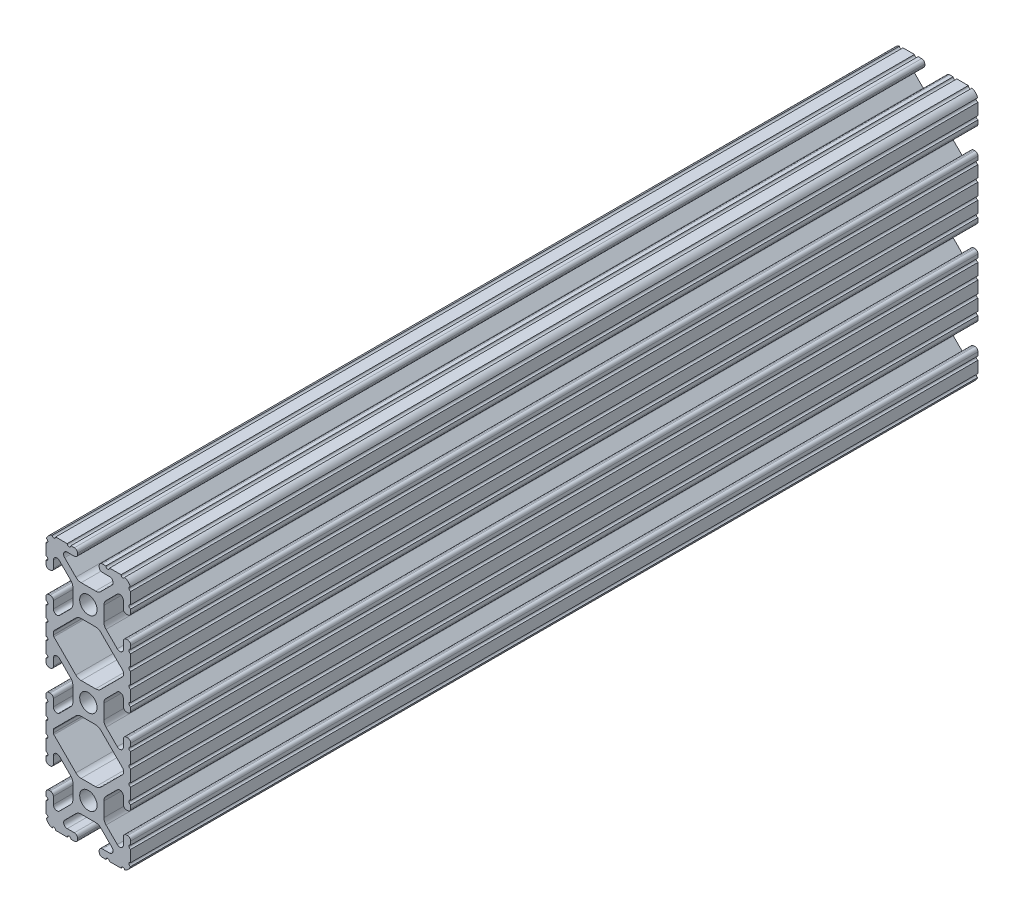
from build123d import *

# Parameters (mm, degrees)
BOSS_EXTRUDE1_DEPTH     = 127
SKETCH5_R               = 0.55245
CUT_EXTRUDE1_DEPTH      = 134.198723718
CUT_EXTRUDE1_DEPTH_BACK = 134.198723718
BOSS_EXTRUDE2_DEPTH     = 127
CUT_EXTRUDE2_DEPTH      = 134.198723718
CUT_EXTRUDE2_DEPTH_BACK = 134.198723718


with BuildPart() as part:
    # Sketch4 → Boss-Extrude1 (new, symmetric)
    with BuildSketch(Plane.XY):
        with BuildLine():
            Line((4.190365, -38.1), (10.11729625, -38.1))
            ThreePointArc((10.11729625, -38.1), (11.943543585, -37.343543585), (12.7, -35.51729625))
            Line((12.7, -35.51729625), (12.7, -29.590365))
            ThreePointArc((12.7, -29.590365), (12.42492494, -28.92627506), (11.760835, -28.6512))
            Line((11.760835, -28.6512), (11.429365, -28.6512))
            ThreePointArc((11.429365, -28.6512), (10.76527506, -28.92627506), (10.4902, -29.590365))
            Line((10.4902, -29.590365), (10.4902, -31.748478019))
            ThreePointArc((10.4902, -31.748478019), (9.830707141, -32.735478831), (8.666460301, -32.503895736))
            Line((8.666460301, -32.503895736), (5.299899128, -29.137334563))
            ThreePointArc((5.299899128, -29.137334563), (4.817571085, -28.415479634), (4.6482, -27.56399369))
            Line((4.6482, -27.56399369), (4.6482, -25.4))
            Line((4.6482, -25.4), (2.6035, -25.4))
            ThreePointArc((2.6035, -25.4), (1.840952505, -27.240952505), (0, -28.0035))
            Line((0, -28.0035), (0, -30.0482))
            Line((0, -30.0482), (2.16399369, -30.0482))
            ThreePointArc((2.16399369, -30.0482), (3.015479634, -30.217571085), (3.737334563, -30.699899128))
            Line((3.737334563, -30.699899128), (7.103895736, -34.066460301))
            ThreePointArc((7.103895736, -34.066460301), (7.335478831, -35.230707141), (6.348478019, -35.8902))
            Line((6.348478019, -35.8902), (4.190365, -35.8902))
            ThreePointArc((4.190365, -35.8902), (3.52627506, -36.16527506), (3.2512, -36.829365))
            Line((3.2512, -36.829365), (3.2512, -37.160835))
            ThreePointArc((3.2512, -37.160835), (3.52627506, -37.82492494), (4.190365, -38.1))
        make_face()
    extrude(amount=BOSS_EXTRUDE1_DEPTH, both=True)

    # Sketch5 → Cut-Extrude1 (cut, two sides)
    with BuildSketch(Plane.XY) as cut_extrude1_sk:
        with Locations((10.356153152, -38.1)):
            Circle(SKETCH5_R)
        with Locations((5.796028019, -38.1)):
            Circle(SKETCH5_R)
        with Locations((12.7, -35.756153152)):
            Circle(SKETCH5_R)
        with Locations((12.7, -31.196028019)):
            Circle(SKETCH5_R)
    extrude(amount=CUT_EXTRUDE1_DEPTH, mode=Mode.SUBTRACT)
    extrude(cut_extrude1_sk.sketch, amount=-CUT_EXTRUDE1_DEPTH_BACK, mode=Mode.SUBTRACT)

    # Mirror1: part across plane


with BuildPart() as part_1:
    add(part.part)
    add(part.part.mirror(Plane(origin=(4.6482, -25.4, 127), x_dir=(0, 0, 1), z_dir=(0, -1, 0))))

    # Sketch6 → Boss-Extrude2 (add, symmetric)
    with BuildSketch(Plane.XY):
        with BuildLine():
            Line((12.7, -14.491396848), (12.7, -12.7))
            Line((12.7, -12.7), (9.803703152, -12.7))
            Line((9.803703152, -12.7), (9.803703152, -15.596296848))
            Line((9.803703152, -15.596296848), (12.7, -15.596296848))
            ThreePointArc((12.7, -15.596296848), (12.14755, -15.043846848), (12.7, -14.491396848))
        make_face()
    extrude(amount=BOSS_EXTRUDE2_DEPTH, both=True)

    # Sketch7 → Cut-Extrude2 (cut, two sides)
    with BuildSketch(Plane.XY) as cut_extrude2_sk:
        with BuildLine():
            Line((5.420615149, -18.416820286), (10.328391141, -13.509044294))
            ThreePointArc((10.328391141, -13.509044294), (10.448147248, -13.329816615), (10.4902, -13.118403152))
            Line((10.4902, -13.118403152), (10.4902, -12.7))
            Line((10.4902, -12.7), (0, -12.7))
            Line((0, -12.7), (5.420615149, -18.416820286))
        make_face()
    extrude(amount=CUT_EXTRUDE2_DEPTH, mode=Mode.SUBTRACT)
    extrude(cut_extrude2_sk.sketch, amount=-CUT_EXTRUDE2_DEPTH_BACK, mode=Mode.SUBTRACT)

    # Mirror2: part across plane


with BuildPart() as part_2:
    add(part_1.part)
    add(part_1.part.mirror(Plane(origin=(4.190365, -12.7, 127), x_dir=(0, 0, 1), z_dir=(0, -1, 0))))

    # SurfaceCut1
    split(bisect_by=Plane(origin=(0, 0, 0), x_dir=(1, 0, 0), z_dir=(0, 1, 0)), keep=Keep.BOTTOM)

    # Mirror3: part across plane


with BuildPart() as part_3:
    add(part_2.part)
    add(part_2.part.mirror(Plane(origin=(0, 0, 0), x_dir=(0, 0, 1), z_dir=(1, 0, 0))))

    # Mirror4: part across plane


with BuildPart() as part_4:
    add(part_3.part)
    add(part_3.part.mirror(Plane.ZX))


solid = part_4.part
